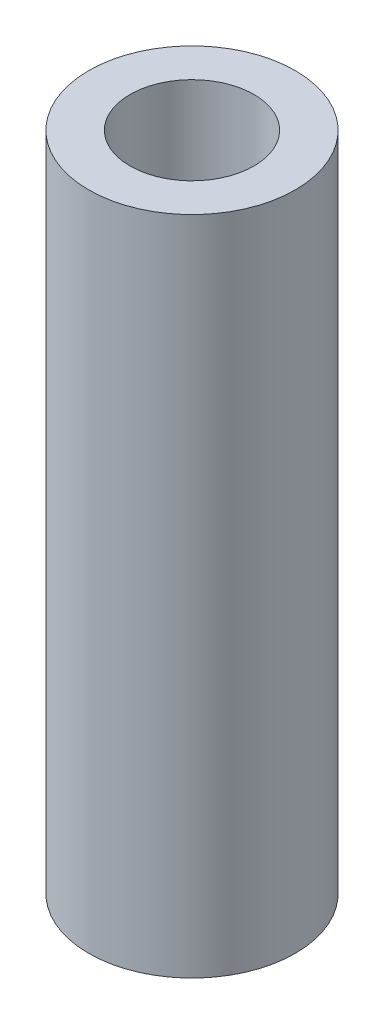
from build123d import *

# Parameters (mm, degrees)
SKETCH_1_R      = 2.5
SKETCH_1_R_2    = 1.5
EXTRUDE_1_DEPTH = 16


with BuildPart() as part:
    # 草图1 → 凸台-拉伸1 (new body)
    with BuildSketch(Plane(origin=(0, 0, 0), x_dir=(1, 0, 0), z_dir=(0, 1, 0))):
        Circle(SKETCH_1_R)
        Circle(SKETCH_1_R_2, mode=Mode.SUBTRACT)
    extrude(amount=EXTRUDE_1_DEPTH)


solid = part.part
